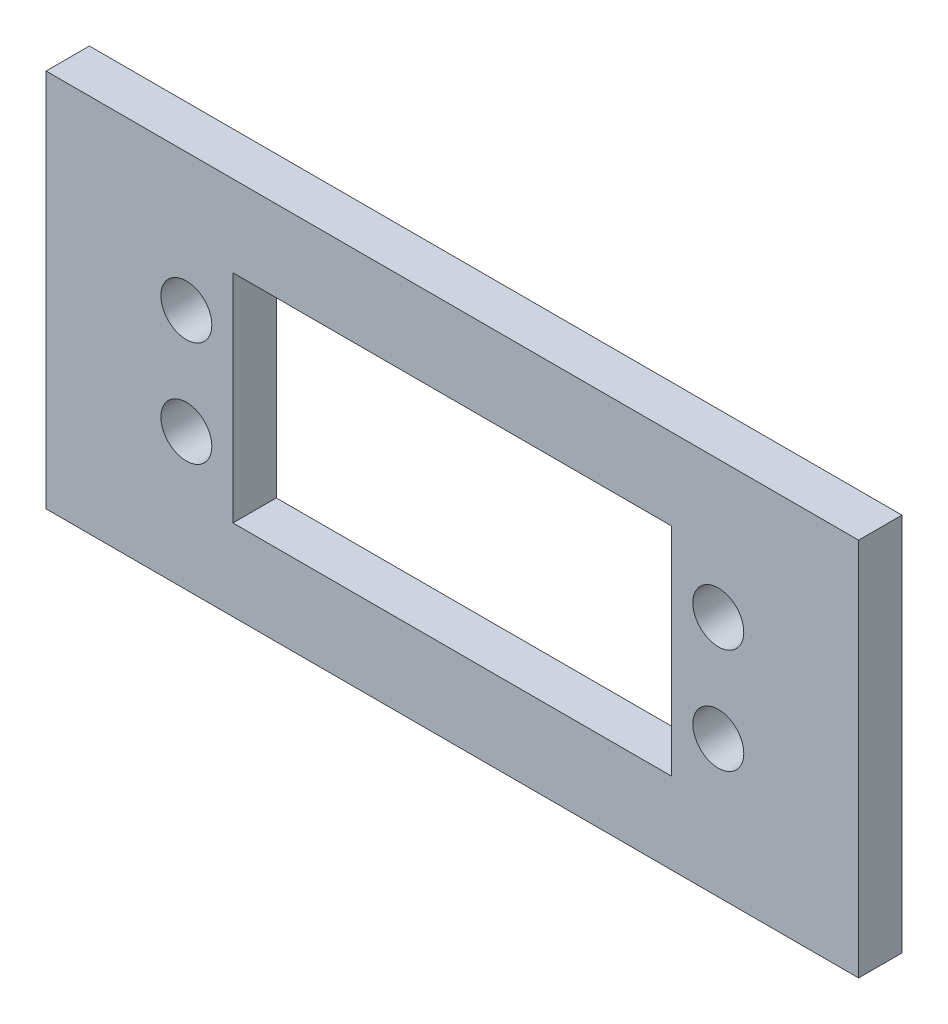
from build123d import *

# Parameters (mm, degrees)
SKETCH1_W           = 75
SKETCH1_H           = 35
SKETCH1_R           = 2.35
SKETCH1_W_2         = 40.5
SKETCH1_H_2         = 20
BOSS_EXTRUDE1_DEPTH = 4


with BuildPart() as part:
    # Sketch1 → Boss-Extrude1 (new body)
    with BuildSketch(Plane.XY):
        Rectangle(SKETCH1_W, SKETCH1_H)
        with Locations((-24.55, 4.85)):
            Circle(SKETCH1_R, mode=Mode.SUBTRACT)
        with Locations((-24.55, -4.85)):
            Circle(SKETCH1_R, mode=Mode.SUBTRACT)
        with Locations((24.55, -4.85)):
            Circle(SKETCH1_R, mode=Mode.SUBTRACT)
        with Locations((24.55, 4.85)):
            Circle(SKETCH1_R, mode=Mode.SUBTRACT)
        Rectangle(SKETCH1_W_2, SKETCH1_H_2, mode=Mode.SUBTRACT)
    extrude(amount=BOSS_EXTRUDE1_DEPTH)


solid = part.part
